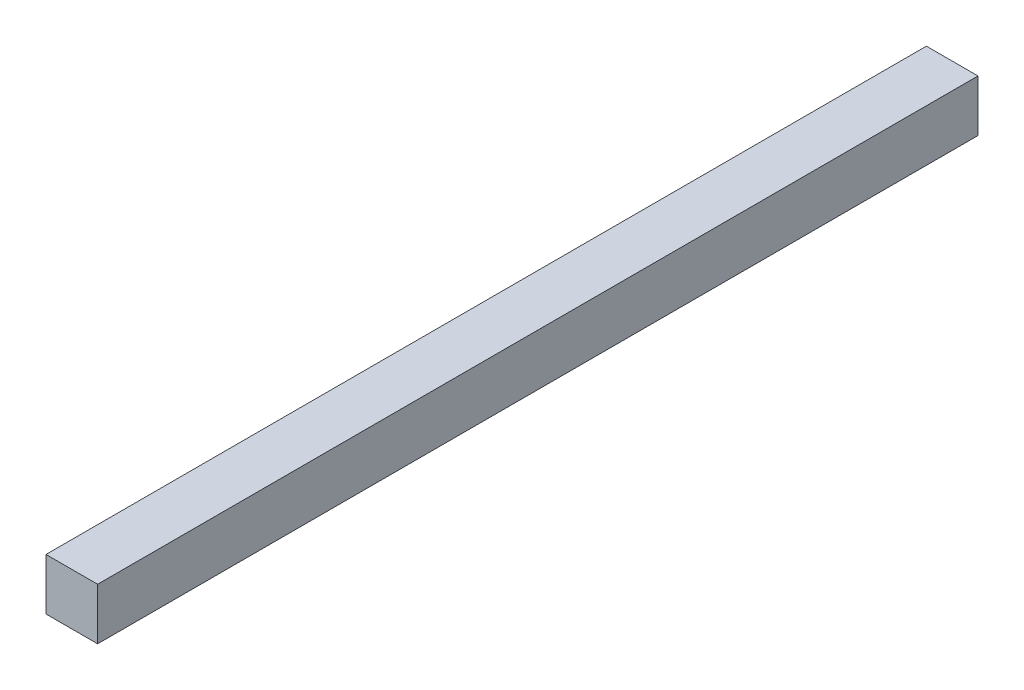
from build123d import *

# Parameters (mm, degrees)
SKETCH1_W           = 35
SKETCH1_H           = 35
BOSS_EXTRUDE1_DEPTH = 597


with BuildPart() as part:
    # Sketch1 → Boss-Extrude1 (new body)
    with BuildSketch(Plane.XY):
        with Locations((17.5, 17.5)):
            Rectangle(SKETCH1_W, SKETCH1_H)
    extrude(amount=BOSS_EXTRUDE1_DEPTH)


solid = part.part
